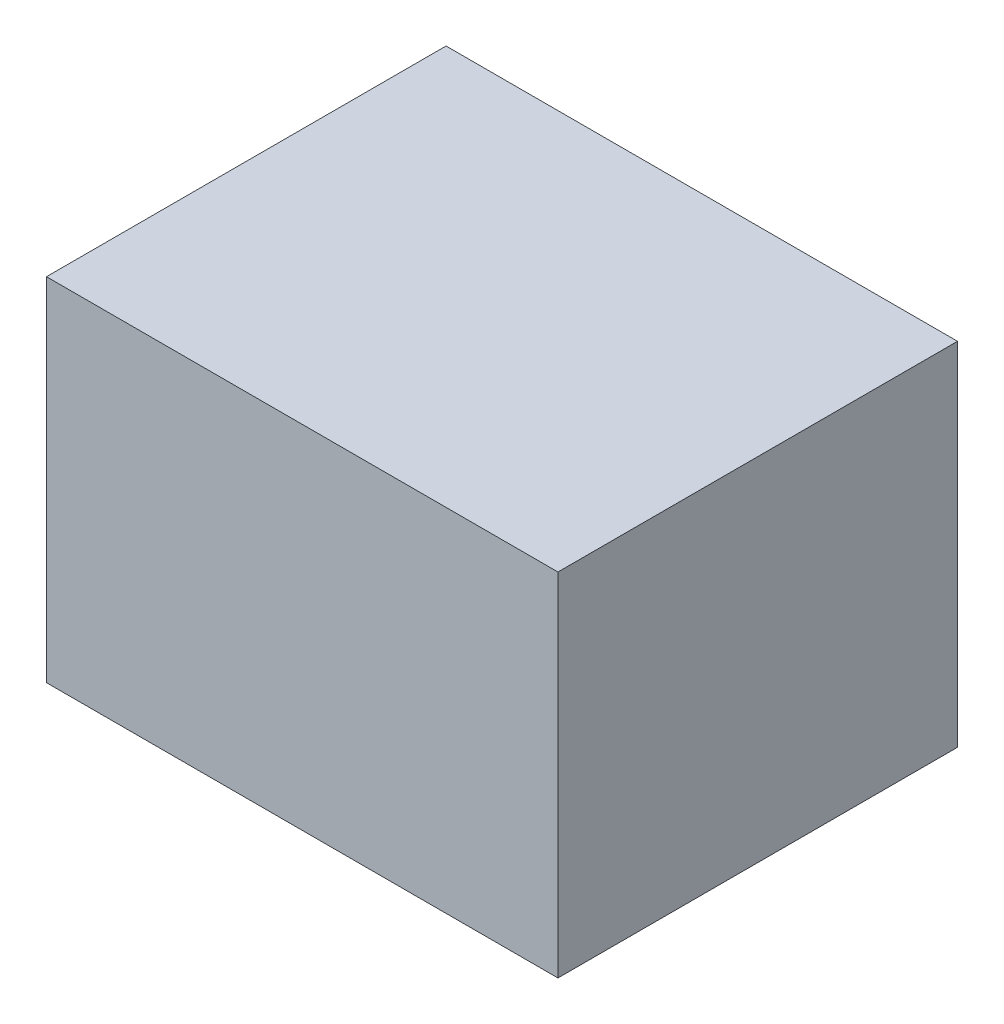
from build123d import *

# Parameters (mm, degrees)
SKETCH1_W           = 406.4
SKETCH1_H           = 317.5
BOSS_EXTRUDE1_DEPTH = 279.4


with BuildPart() as part:
    # Sketch1 → Boss-Extrude1 (new body)
    with BuildSketch(Plane(origin=(0, 0, 0), x_dir=(1, 0, 0), z_dir=(0, 1, 0))):
        Rectangle(SKETCH1_W, SKETCH1_H)
    extrude(amount=BOSS_EXTRUDE1_DEPTH)


solid = part.part
